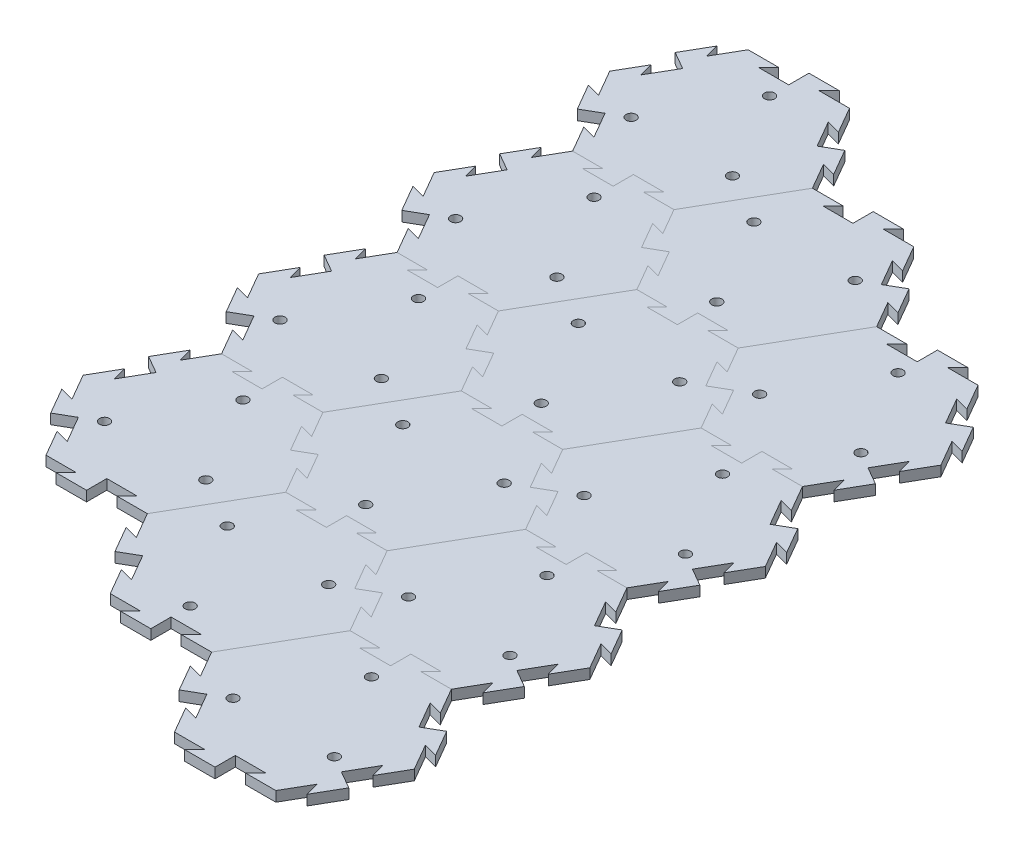
from build123d import *

# Parameters (mm, degrees)
BOSS_EXTRUDE1_DEPTH = 6.35
SKETCH9_R           = 3.175
CUT_EXTRUDE3_DEPTH  = 7.35
CIRPATTERN6_COUNT   = 3
CUT_EXTRUDE4_DEPTH  = 7.35
BOSS_EXTRUDE4_DEPTH = 6.35
CIRPATTERN7_COUNT   = 6
CUT_EXTRUDE5_DEPTH  = 7.35
BOSS_EXTRUDE5_DEPTH = 6.35
CIRPATTERN8_COUNT   = 6
CUT_EXTRUDE6_DEPTH  = 7.35
BOSS_EXTRUDE6_DEPTH = 6.35
CIRPATTERN9_COUNT   = 6
LPATTERN1_COUNT     = 4
LPATTERN1_PITCH     = 109.985226308


with BuildPart() as part:
    # Sketch1 → Boss-Extrude1 (new body)
    with BuildSketch(Plane(origin=(0, 0, 0), x_dir=(1, 0, 0), z_dir=(0, 1, 0))):
        Polygon((63.5, 0), (31.75, 54.99261314), (-31.75, 54.99261314), (-63.5, 0), (-31.75, -54.99261314), (31.75, -54.99261314), align=None)
    extrude(amount=-BOSS_EXTRUDE1_DEPTH)

    # Sketch9 → Cut-Extrude3 (cut, through all)
    with BuildSketch(Plane(origin=(0, 0, 0), x_dir=(1, 0, 0), z_dir=(0, 1, 0))):
        with Locations((-31.75, -18.330871047)):
            Circle(SKETCH9_R)
    cut_extrude3 = extrude(amount=-CUT_EXTRUDE3_DEPTH, mode=Mode.SUBTRACT)

    # CirPattern6: Cut-Extrude3 ×3 about axis
    cirpattern6_axis = Axis((0, 0, 0), (0, 1, 0))
    for i in range(1, CIRPATTERN6_COUNT):
        add(cut_extrude3.rotate(cirpattern6_axis, i * 360 / CIRPATTERN6_COUNT), mode=Mode.SUBTRACT)


with BuildPart() as body_2:
    # Mirror3: mirrored copy
    add(part.part.mirror(Plane(origin=(31.75, -6.35, 54.99261314), x_dir=(-0.5, 0, 0.866025404), z_dir=(0.866025404, 0, 0.5))))


with BuildPart() as part_1:
    add(part.part)

    # Sketch10 → Cut-Extrude4 (cut, through all)
    with BuildSketch(Plane(origin=(0, 0, 0), x_dir=(1, 0, 0), z_dir=(0, 1, 0))):
        Polygon((41.275, 38.494829198), (32.600738686, 40.819090512), (42.125738686, 24.32130657), (47.625, 27.49630657), align=None)
    cut_extrude4 = extrude(amount=-CUT_EXTRUDE4_DEPTH, mode=Mode.SUBTRACT)

    # Sketch11 → Boss-Extrude4 (add)
    with BuildSketch(Plane(origin=(0, 0, 0), x_dir=(1, 0, 0), z_dir=(0, 1, 0))):
        Polygon((47.625, 27.49630657), (53.124261314, 30.67130657), (62.649261314, 14.173522628), (53.975, 16.497783942), align=None)
    boss_extrude4 = extrude(amount=-BOSS_EXTRUDE4_DEPTH)

    # CirPattern7: Cut-Extrude4, Boss-Extrude4 ×6 about axis, 1 skipped
    cirpattern7_axis = Axis((0, 0, 0), (0, 1, 0))
    add([cut_extrude4.rotate(cirpattern7_axis, i * 360 / CIRPATTERN7_COUNT) for i in range(1, CIRPATTERN7_COUNT) if i not in (5,)], mode=Mode.SUBTRACT)
    add([boss_extrude4.rotate(cirpattern7_axis, i * 360 / CIRPATTERN7_COUNT) for i in range(1, CIRPATTERN7_COUNT) if i not in (5,)])


with BuildPart() as body_3:
    # Mirror4: mirrored copy
    add(body_2.part.mirror(Plane(origin=(158.75, -6.35, 54.99261314), x_dir=(-0.5, 0, 0.866025404), z_dir=(0.866025404, 0, 0.5))))

    # Sketch16 → Cut-Extrude6 (cut, through all)
    with BuildSketch(Plane(origin=(0, 0, 0), x_dir=(1, 0, 0), z_dir=(0, 1, 0))):
        Polygon((231.775, -71.490397082), (223.100738686, -69.166135768), (232.625738686, -85.66391971), (238.125, -82.48891971), align=None)
    cut_extrude6 = extrude(amount=-CUT_EXTRUDE6_DEPTH, mode=Mode.SUBTRACT)

    # Sketch17 → Boss-Extrude6 (add)
    with BuildSketch(Plane(origin=(0, 0, 0), x_dir=(1, 0, 0), z_dir=(0, 1, 0))):
        Polygon((238.125, -82.48891971), (243.624261314, -79.31391971), (253.149261314, -95.811703653), (244.475, -93.487442339), align=None)
    boss_extrude6 = extrude(amount=-BOSS_EXTRUDE6_DEPTH)

    # CirPattern9: Cut-Extrude6, Boss-Extrude6 ×6 about axis, 1 skipped
    cirpattern9_axis = Axis((190.5, 0, 109.985226281), (0, 1, 0))
    add([cut_extrude6.rotate(cirpattern9_axis, i * 360 / CIRPATTERN9_COUNT) for i in range(1, CIRPATTERN9_COUNT) if i not in (2,)], mode=Mode.SUBTRACT)
    add([boss_extrude6.rotate(cirpattern9_axis, i * 360 / CIRPATTERN9_COUNT) for i in range(1, CIRPATTERN9_COUNT) if i not in (2,)])


with BuildPart() as body_2_1:
    add(body_2.part)

    # Sketch13 → Cut-Extrude5 (cut, through all)
    with BuildSketch(Plane(origin=(0, 0, 0), x_dir=(1, 0, 0), z_dir=(0, 1, 0))):
        Polygon((136.525, -16.497783942), (127.850738686, -14.173522628), (137.375738686, -30.67130657), (142.875, -27.49630657), align=None)
    cut_extrude5 = extrude(amount=-CUT_EXTRUDE5_DEPTH, mode=Mode.SUBTRACT)

    # Sketch14 → Boss-Extrude5 (add)
    with BuildSketch(Plane(origin=(0, 0, 0), x_dir=(1, 0, 0), z_dir=(0, 1, 0))):
        Polygon((142.875, -27.49630657), (148.374261314, -24.32130657), (157.899261314, -40.819090512), (149.225, -38.494829198), align=None)
    boss_extrude5 = extrude(amount=-BOSS_EXTRUDE5_DEPTH)

    # CirPattern8: Cut-Extrude5, Boss-Extrude5 ×6 about axis, 2 skipped
    cirpattern8_axis = Axis((95.25, 0, 54.99261314), (0, 1, 0))
    add([cut_extrude5.rotate(cirpattern8_axis, i * 360 / CIRPATTERN8_COUNT) for i in range(1, CIRPATTERN8_COUNT) if i not in (2, 5)], mode=Mode.SUBTRACT)
    add([boss_extrude5.rotate(cirpattern8_axis, i * 360 / CIRPATTERN8_COUNT) for i in range(1, CIRPATTERN8_COUNT) if i not in (2, 5)])


with BuildPart() as lpattern1_1:
    # LPattern1: pattern copy
    add(part_1.part.moved(Location(Vector(0, 0, -1) * (1 * LPATTERN1_PITCH))))


with BuildPart() as lpattern1_2:
    # LPattern1: pattern copy
    add(part_1.part.moved(Location(Vector(0, 0, -1) * (2 * LPATTERN1_PITCH))))


with BuildPart() as lpattern1_3:
    # LPattern1: pattern copy
    add(part_1.part.moved(Location(Vector(0, 0, -1) * (3 * LPATTERN1_PITCH))))


with BuildPart() as lpattern1_4:
    # LPattern1: pattern copy
    add(body_3.part.moved(Location(Vector(0, 0, -1) * (1 * LPATTERN1_PITCH))))


with BuildPart() as lpattern1_5:
    # LPattern1: pattern copy
    add(body_3.part.moved(Location(Vector(0, 0, -1) * (2 * LPATTERN1_PITCH))))


with BuildPart() as lpattern1_6:
    # LPattern1: pattern copy
    add(body_3.part.moved(Location(Vector(0, 0, -1) * (3 * LPATTERN1_PITCH))))


with BuildPart() as lpattern1_7:
    # LPattern1: pattern copy
    add(body_2_1.part.moved(Location(Vector(0, 0, -1) * (1 * LPATTERN1_PITCH))))


with BuildPart() as lpattern1_8:
    # LPattern1: pattern copy
    add(body_2_1.part.moved(Location(Vector(0, 0, -1) * (2 * LPATTERN1_PITCH))))


with BuildPart() as lpattern1_9:
    # LPattern1: pattern copy
    add(body_2_1.part.moved(Location(Vector(0, 0, -1) * (3 * LPATTERN1_PITCH))))


solid = Compound([part_1.part, body_3.part, body_2_1.part, lpattern1_1.part, lpattern1_2.part, lpattern1_3.part, lpattern1_4.part, lpattern1_5.part, lpattern1_6.part, lpattern1_7.part, lpattern1_8.part, lpattern1_9.part])
